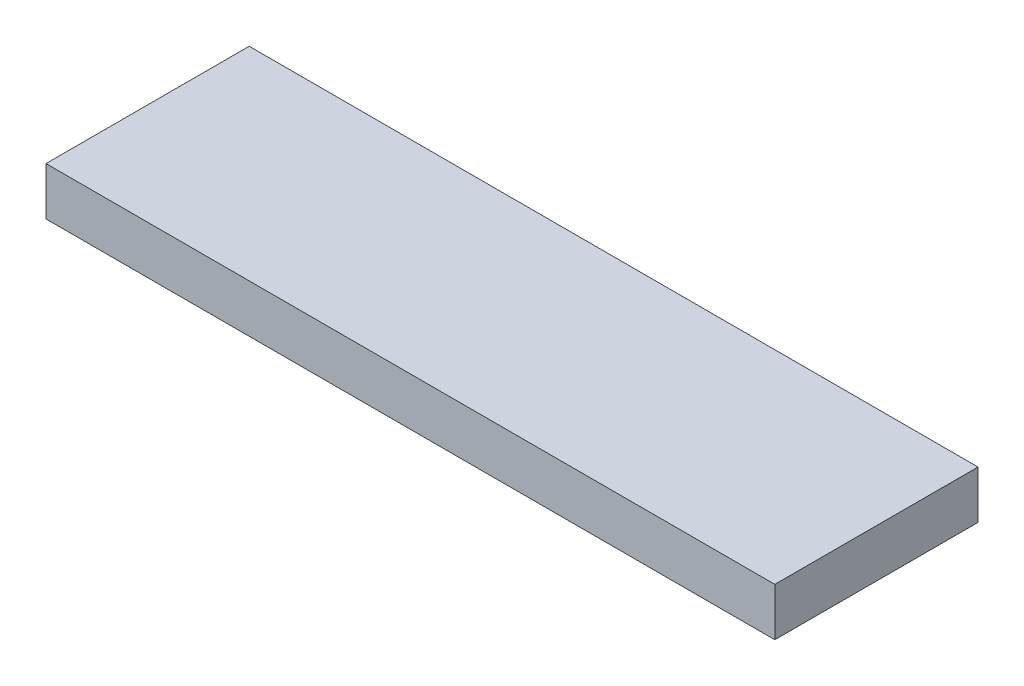
from build123d import *

# Parameters (mm, degrees)
SKIZZE1_W                       = 30.374475099
SKIZZE1_H                       = 8.468379456
AUFSATZ_LINEAR_AUSTRAGEN1_DEPTH = 2


with BuildPart() as part:
    # Skizze1 → Aufsatz-Linear austragen1 (new body)
    with BuildSketch(Plane(origin=(0, 0, 0), x_dir=(1, 0, 0), z_dir=(0, 1, 0))):
        with Locations((15.18723755, -4.234189728)):
            Rectangle(SKIZZE1_W, SKIZZE1_H)
    extrude(amount=AUFSATZ_LINEAR_AUSTRAGEN1_DEPTH)


solid = part.part
